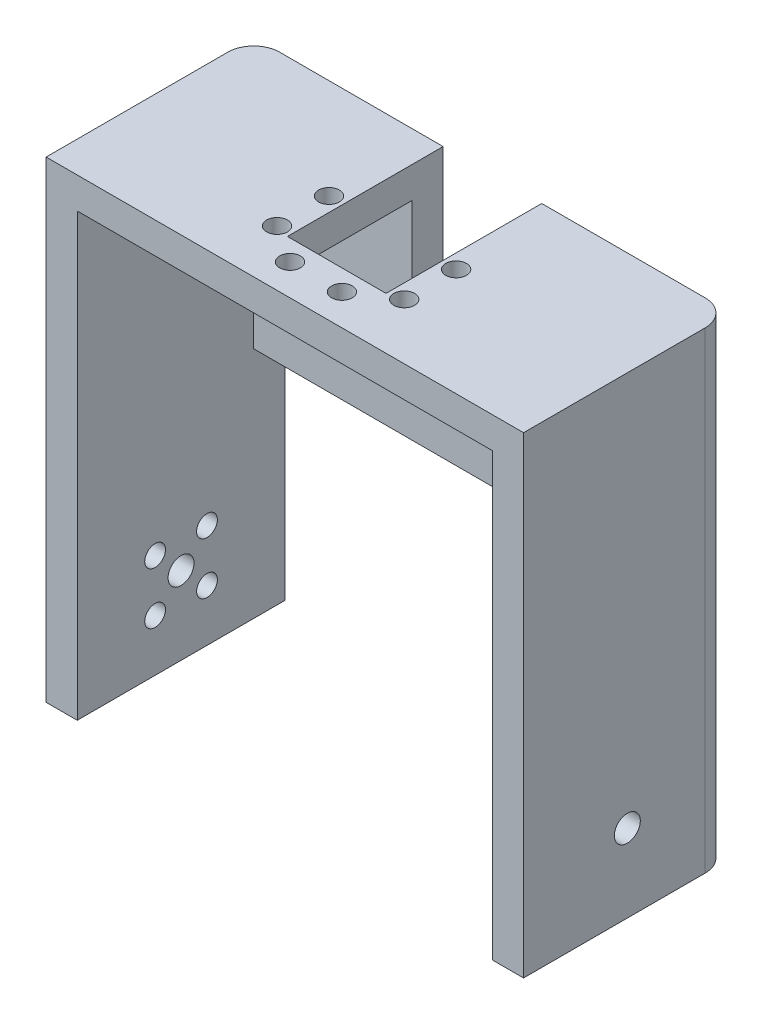
from build123d import *

# Parameters (mm, degrees)
SALIENTE_EXTRUIR1_DEPTH    = 40
CROQUIS5_W                 = 40
CROQUIS5_H                 = 10
CORTAR_EXTRUIR2_DEPTH      = 40
SALIENTE_EXTRUIR2_DEPTH    = 40
CROQUIS6_R                 = 2
CROQUIS6_W                 = 19
CROQUIS6_H                 = 42
CORTAR_EXTRUIR3_DEPTH      = 3
CORTAR_EXTRUIR3_DEPTH_BACK = 40
CROQUIS9_W                 = 6
CROQUIS9_H                 = 40
SALIENTE_EXTRUIR3_DEPTH    = 60
CROQUIS10_W                = 6
CROQUIS10_H                = 40
SALIENTE_EXTRUIR4_DEPTH    = 50
CROQUIS11_R                = 2.5
CORTAR_EXTRUIR4_DEPTH      = 1
CORTAR_EXTRUIR4_DEPTH_BACK = 93
CROQUIS12_W                = 80
CROQUIS12_H                = 6
SALIENTE_EXTRUIR5_DEPTH    = 40
CROQUIS13_W                = 19
CROQUIS13_H                = 20.4
CORTAR_EXTRUIR5_DEPTH      = 40
CROQUIS14_R                = 2
CROQUIS14_R_2              = 2.5
CORTAR_EXTRUIR6_DEPTH      = 40
REDONDEO3_R                = 5


with BuildPart() as part:
    # Croquis2 → Saliente-Extruir1 (new body)
    with BuildSketch(Plane.XY):
        Polygon((-31.145916957, -11.001243781), (-31.145916957, 23.998756219), (48.854083043, 23.998756219), (48.854083043, -11.001243781), (52.854083043, -11.001243781), (52.854083043, 27.998756219), (-35.145916957, 27.998756219), (-35.145916957, -11.001243781), align=None)
    extrude(amount=SALIENTE_EXTRUIR1_DEPTH)

    # Croquis5 → Cortar-Extruir2 (cut)
    with BuildSketch(Plane.ZY.offset(35.145916957)):
        with Locations((20, -6.001243781)):
            Rectangle(CROQUIS5_W, CROQUIS5_H)
    extrude(amount=-CORTAR_EXTRUIR2_DEPTH, mode=Mode.SUBTRACT)

    # Croquis7 → Saliente-Extruir2 (add)
    with BuildSketch(Plane.XY.offset(40)):
        Polygon((-35.145916957, -1.001243781), (-37.145916957, -1.001243781), (-37.145916957, 29.998756219), (54.854083043, 29.998756219), (54.854083043, -11.001243781), (52.854083043, -11.001243781), (52.854083043, 27.998756219), (-35.145916957, 27.998756219), align=None)
    extrude(amount=-SALIENTE_EXTRUIR2_DEPTH)

    # Croquis6 → Cortar-Extruir3 (cut, two sides)
    with BuildSketch(Plane(origin=(0, 27.998756219, 0), x_dir=(1, 0, 0), z_dir=(0, 1, 0))) as cortar_extruir3_sk:
        with Locations((13.854083043, -34)):
            Circle(CROQUIS6_R)
        with Locations((3.854083043, -34)):
            Circle(CROQUIS6_R)
        with Locations((-3.395916957, -29.25)):
            Circle(CROQUIS6_R)
        with Locations((-3.395916957, -19.25)):
            Circle(CROQUIS6_R)
        with Locations((21.104083043, -19.25)):
            Circle(CROQUIS6_R)
        with Locations((21.104083043, -29.25)):
            Circle(CROQUIS6_R)
        with Locations((8.854083043, -9)):
            Rectangle(CROQUIS6_W, CROQUIS6_H)
    extrude(amount=CORTAR_EXTRUIR3_DEPTH, mode=Mode.SUBTRACT)
    extrude(cortar_extruir3_sk.sketch, amount=-CORTAR_EXTRUIR3_DEPTH_BACK, mode=Mode.SUBTRACT)

    # Croquis9 → Saliente-Extruir3 (add)
    with BuildSketch(Plane.XZ.offset(1.001243781)):
        with Locations((-34.145916957, 20)):
            Rectangle(CROQUIS9_W, CROQUIS9_H)
    extrude(amount=SALIENTE_EXTRUIR3_DEPTH)

    # Croquis10 → Saliente-Extruir4 (add)
    with BuildSketch(Plane.XZ.offset(11.001243781)):
        with Locations((51.854083043, 20)):
            Rectangle(CROQUIS10_W, CROQUIS10_H)
    extrude(amount=SALIENTE_EXTRUIR4_DEPTH)

    # Croquis11 → Cortar-Extruir4 (cut, two sides)
    with BuildSketch(Plane.ZY.offset(37.145916957)) as cortar_extruir4_sk:
        with Locations((20, -46.001243781)):
            Circle(CROQUIS11_R)
    extrude(amount=CORTAR_EXTRUIR4_DEPTH, mode=Mode.SUBTRACT)
    extrude(cortar_extruir4_sk.sketch, amount=-CORTAR_EXTRUIR4_DEPTH_BACK, mode=Mode.SUBTRACT)

    # Croquis12 → Saliente-Extruir5 (add)
    with BuildSketch(Plane.XZ.offset(-23.998756219)):
        with Locations((8.854083043, 3)):
            Rectangle(CROQUIS12_W, CROQUIS12_H)
    extrude(amount=SALIENTE_EXTRUIR5_DEPTH)

    # Croquis13 → Cortar-Extruir5 (cut)
    with BuildSketch(Plane(origin=(0, 0, 0), x_dir=(-1, 0, 0), z_dir=(0, 0, -1))):
        with Locations((-8.854083043, 13.798756219)):
            Rectangle(CROQUIS13_W, CROQUIS13_H)
    extrude(amount=-CORTAR_EXTRUIR5_DEPTH, mode=Mode.SUBTRACT)

    # Croquis14 → Cortar-Extruir6 (cut)
    with BuildSketch(Plane.ZY.offset(37.145916957)):
        with Locations((25, -51.001243781)):
            Circle(CROQUIS14_R)
        with Locations((25, -41.001243781)):
            Circle(CROQUIS14_R)
        with Locations((15, -51.001243781)):
            Circle(CROQUIS14_R)
        with Locations((15, -41.001243781)):
            Circle(CROQUIS14_R)
        with Locations((20, -46.001243781)):
            Circle(CROQUIS14_R_2)
    extrude(amount=-CORTAR_EXTRUIR6_DEPTH, mode=Mode.SUBTRACT)

    # Redondeo3
    redondeo3_edges = [part.edges().sort_by_distance(p)[0] for p in [
        (-37.145916957, -15.501243781, 0),
        (54.854083043, -15.501243781, 0),
    ]]
    fillet(redondeo3_edges, radius=REDONDEO3_R)


solid = part.part
